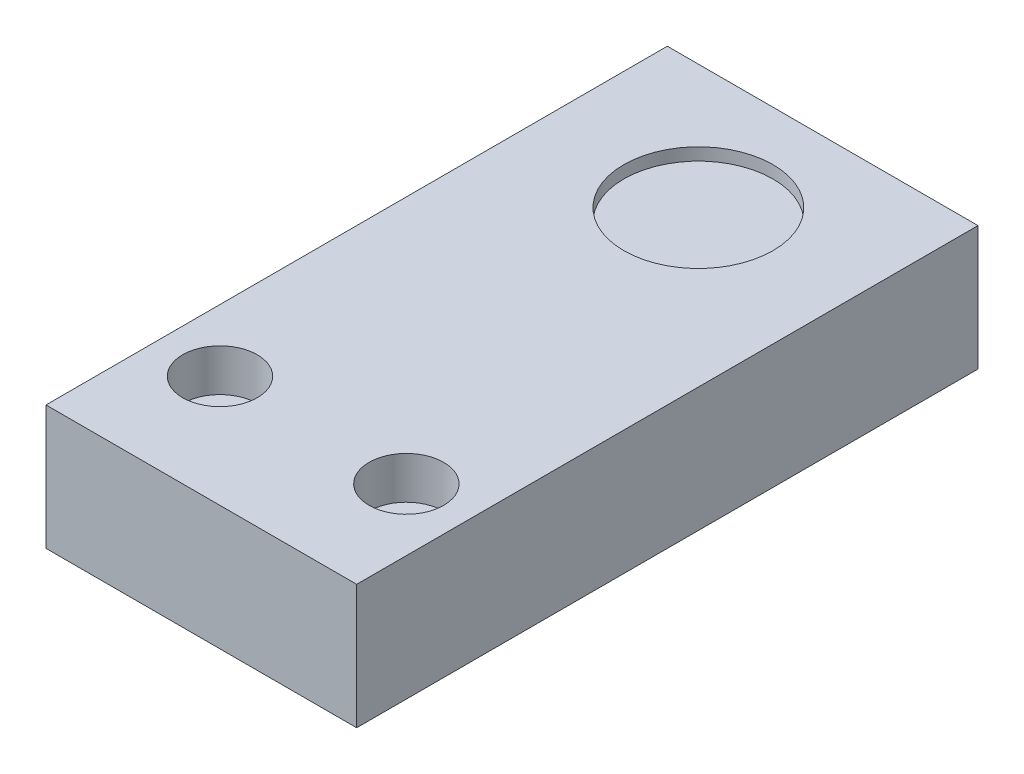
from build123d import *

# Parameters (mm, degrees)
SKETCH_1_W                = 25
SKETCH_1_H                = 50
EXTRUDE_1_DEPTH           = 10
HOLE_WIZARD_1_D           = 3.2
HOLE_WIZARD_1_CBORE_D     = 6
HOLE_WIZARD_1_CBORE_DEPTH = 3.4
SKETCH_5_R                = 6
CUT_EXTRUDE_1_DEPTH       = 1


with BuildPart() as part:
    # 草图1 → 凸台-拉伸1 (new body)
    with BuildSketch(Plane(origin=(0, 0, 0), x_dir=(1, 0, 0), z_dir=(0, 1, 0))):
        Rectangle(SKETCH_1_W, SKETCH_1_H)
    extrude(amount=EXTRUDE_1_DEPTH)

    # 打孔尺寸(%根据)内六角圆柱头螺钉的类型1 (through all)
    with Locations(Plane(origin=(0, 10, 0), x_dir=(1, 0, 0), z_dir=(0, 1, 0))):
        with Locations((-7.5, -16), (7.5, -16)):
            CounterBoreHole(HOLE_WIZARD_1_D / 2, HOLE_WIZARD_1_CBORE_D / 2, HOLE_WIZARD_1_CBORE_DEPTH)

    # 草图5 → 切除-拉伸1 (cut)
    with BuildSketch(Plane(origin=(0, 10, 0), x_dir=(1, 0, 0), z_dir=(0, 1, 0))):
        with Locations((0, 15)):
            Circle(SKETCH_5_R)
    extrude(amount=-CUT_EXTRUDE_1_DEPTH, mode=Mode.SUBTRACT)


solid = part.part
